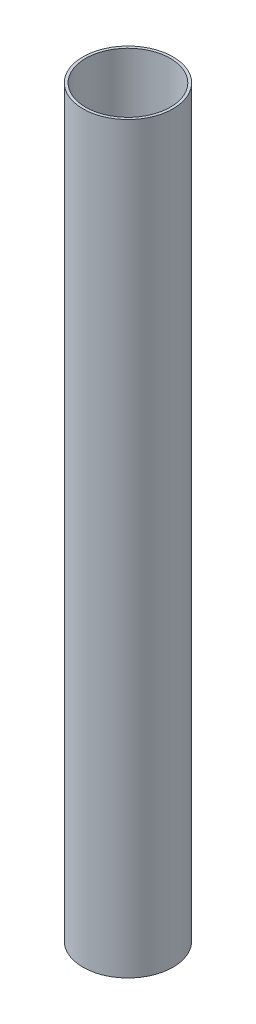
from build123d import *

# Parameters (mm, degrees)
SKETCH1_R           = 50
SKETCH1_R_2         = 47
BOSS_EXTRUDE1_DEPTH = 825


with BuildPart() as part:
    # Sketch1 → Boss-Extrude1 (new body)
    with BuildSketch(Plane(origin=(0, 0, 0), x_dir=(1, 0, 0), z_dir=(0, 1, 0))):
        Circle(SKETCH1_R)
        Circle(SKETCH1_R_2, mode=Mode.SUBTRACT)
    extrude(amount=BOSS_EXTRUDE1_DEPTH)


solid = part.part
